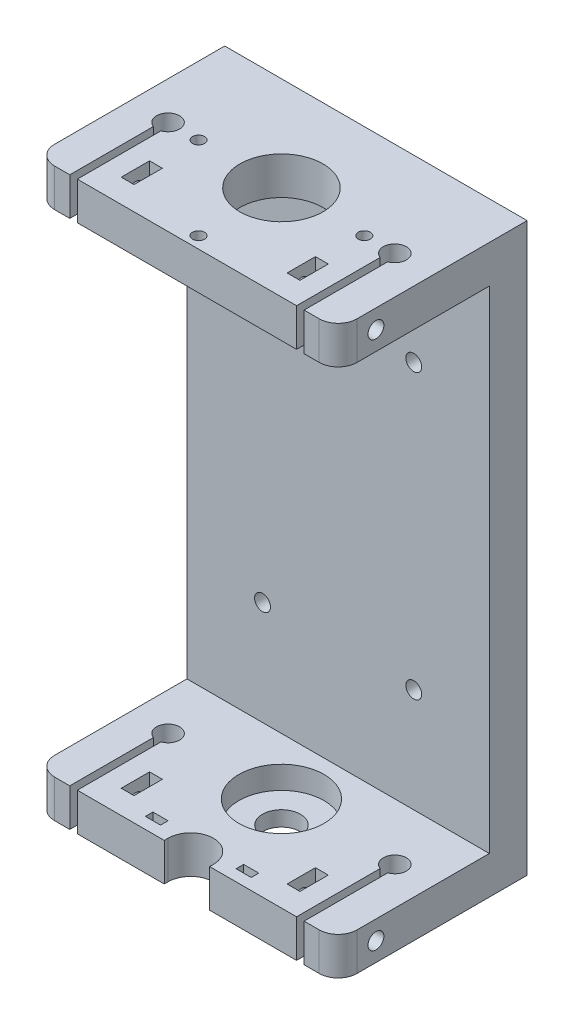
from build123d import *

# Parameters (mm, degrees)
SKETCH_1_W           = 80
SKETCH_1_H           = 150
EXTRUDE_1_DEPTH      = 10
SKETCH_4_R           = 11.25
EXTRUDE_3_DEPTH      = 10
SKETCH_5_R           = 11.25
SKETCH_5_R_2         = 5
EXTRUDE_4_DEPTH      = 4
SKETCH_6_R           = 2.1
CUT_EXTRUDE_1_DEPTH  = 24
SKETCH_7_W           = 3.4
SKETCH_7_H           = 7.5
CUT_EXTRUDE_2_DEPTH  = 24
SKETCH_8_R           = 2.1
CUT_EXTRUDE_3_DEPTH  = 24
SKETCH_9_W           = 80
SKETCH_9_H           = 40
SKETCH_9_R           = 11
SKETCH_9_R_2         = 1.6
EXTRUDE_5_DEPTH      = 10
FILLET_1_R           = 5
SKETCH_10_W          = 3.4
SKETCH_10_H          = 7.5
CUT_EXTRUDE_5_DEPTH  = 10
SKETCH_11_R          = 2.1
CUT_EXTRUDE_6_DEPTH  = 24
SKETCH_12_R          = 2.1
CUT_EXTRUDE_7_DEPTH  = 24
SKETCH_14_W          = 4
SKETCH_14_H          = 2
CUT_EXTRUDE_9_DEPTH  = 10
SKETCH_16_R          = 2.1
CUT_EXTRUDE_10_DEPTH = 11


with BuildPart() as part:
    # 草圖1 → 填料-伸長1 (new body)
    with BuildSketch(Plane.XY):
        Rectangle(SKETCH_1_W, SKETCH_1_H)
    extrude(amount=EXTRUDE_1_DEPTH)

    # 草圖4 → 填料-伸長3 (add)
    with BuildSketch(Plane.XZ.offset(75)):
        with BuildLine():
            ThreePointArc((-6, 49), (0, 43), (6, 49))
            Line((6, 49), (6, 50))
            Line((6, 50), (29, 50))
            Line((29, 50), (29, 27.881405907))
            ThreePointArc((29, 27.881405907), (30, 21.95), (31, 27.881405907))
            Line((31, 27.881405907), (31, 50))
            Line((31, 50), (40, 50))
            Line((40, 50), (40, 10))
            Line((40, 10), (-40, 10))
            Line((-40, 10), (-40, 50))
            Line((-40, 50), (-31, 50))
            Line((-31, 50), (-31, 27.881405907))
            ThreePointArc((-31, 27.881405907), (-30, 21.95), (-29, 27.881405907))
            Line((-29, 27.881405907), (-29, 50))
            Line((-29, 50), (-6, 50))
            Line((-6, 50), (-6, 49))
        make_face()
        with Locations((0, 25)):
            Circle(SKETCH_4_R, mode=Mode.SUBTRACT)
    extrude(amount=-EXTRUDE_3_DEPTH)

    # 草圖5 → 填料-伸長4 (add)
    with BuildSketch(Plane.XZ.offset(75)):
        with Locations((0, 25)):
            Circle(SKETCH_5_R)
        with Locations((0, 25)):
            Circle(SKETCH_5_R_2, mode=Mode.SUBTRACT)
    extrude(amount=-EXTRUDE_4_DEPTH)

    # 草圖6 → 除料-伸長1 (cut)
    with BuildSketch(Plane(origin=(40, 0, 0), x_dir=(0, 0, -1), z_dir=(1, 0, 0))):
        with Locations((-40, -70)):
            Circle(SKETCH_6_R)
    extrude(amount=-CUT_EXTRUDE_1_DEPTH, mode=Mode.SUBTRACT)

    # 草圖7 → 除料-伸長2 (cut)
    with BuildSketch(Plane.XZ.offset(75)):
        with Locations((-21.943112787, 40)):
            Rectangle(SKETCH_7_W, SKETCH_7_H)
        with Locations((21.943112787, 40)):
            Rectangle(SKETCH_7_W, SKETCH_7_H)
    extrude(amount=-CUT_EXTRUDE_2_DEPTH, mode=Mode.SUBTRACT)

    # 草圖8 → 除料-伸長3 (cut)
    with BuildSketch(Plane.ZY.offset(40)):
        with Locations((40, -70)):
            Circle(SKETCH_8_R)
    extrude(amount=-CUT_EXTRUDE_3_DEPTH, mode=Mode.SUBTRACT)

    # 草圖9 → 填料-伸長5 (add)
    with BuildSketch(Plane(origin=(0, 75, 0), x_dir=(1, 0, 0), z_dir=(0, 1, 0))):
        with Locations((0, -30)):
            Rectangle(SKETCH_9_W, SKETCH_9_H)
        with Locations((0, -25)):
            Circle(SKETCH_9_R, mode=Mode.SUBTRACT)
        with Locations((-21.920310217, -25)):
            Circle(SKETCH_9_R_2, mode=Mode.SUBTRACT)
        with Locations((0, -46.920310217)):
            Circle(SKETCH_9_R_2, mode=Mode.SUBTRACT)
        with Locations((21.920310217, -25)):
            Circle(SKETCH_9_R_2, mode=Mode.SUBTRACT)
    extrude(amount=-EXTRUDE_5_DEPTH)

    # 圓角1
    fillet_1_edges = [part.edges().sort_by_distance(p)[0] for p in [
        (40, 70, 50),
        (-40, 70, 50),
        (40, -70, 50),
        (-40, -70, 50),
    ]]
    fillet(fillet_1_edges, radius=FILLET_1_R)

    # 草圖10 → 除料-伸長5 (cut)
    with BuildSketch(Plane(origin=(0, 75, 0), x_dir=(1, 0, 0), z_dir=(0, 1, 0))):
        with BuildLine():
            Line((-30.992105359, -72.117230176), (-29, -72.117230176))
            Line((-29, -72.117230176), (-29, -27.881405907))
            ThreePointArc((-29, -27.881405907), (-30.004176302, -21.950002859), (-30.992105359, -27.884133658))
            Line((-30.992105359, -27.884133658), (-30.992105359, -72.117230176))
        make_face()
        with BuildLine():
            Line((29.001577897, -72.118320527), (31, -72.118320527))
            Line((31, -72.118320527), (31, -27.881405907))
            ThreePointArc((31, -27.881405907), (29.999164969, -21.950000114), (29.001577897, -27.881953036))
            Line((29.001577897, -27.881953036), (29.001577897, -72.118320527))
        make_face()
        with Locations((-21.943112787, -40)):
            Rectangle(SKETCH_10_W, SKETCH_10_H)
        with Locations((21.943112787, -40)):
            Rectangle(SKETCH_10_W, SKETCH_10_H)
    extrude(amount=-CUT_EXTRUDE_5_DEPTH, mode=Mode.SUBTRACT)

    # 草圖11 → 除料-伸長6 (cut)
    with BuildSketch(Plane(origin=(40, 0, 0), x_dir=(0, 0, -1), z_dir=(1, 0, 0))):
        with Locations((-40, 70)):
            Circle(SKETCH_11_R)
    extrude(amount=-CUT_EXTRUDE_6_DEPTH, mode=Mode.SUBTRACT)

    # 草圖12 → 除料-伸長7 (cut)
    with BuildSketch(Plane.ZY.offset(40)):
        with Locations((40, 70)):
            Circle(SKETCH_12_R)
    extrude(amount=-CUT_EXTRUDE_7_DEPTH, mode=Mode.SUBTRACT)

    # 草圖14 → 除料-伸長9 (cut)
    with BuildSketch(Plane.XZ.offset(75)):
        with Locations((-12, 46)):
            Rectangle(SKETCH_14_W, SKETCH_14_H)
        with Locations((12, 46)):
            Rectangle(SKETCH_14_W, SKETCH_14_H)
    extrude(amount=-CUT_EXTRUDE_9_DEPTH, mode=Mode.SUBTRACT)

    # 草圖16 → 除料-伸長10 (cut, through all)
    with BuildSketch(Plane.XY.offset(10)):
        with Locations((-20, 37.5)):
            Circle(SKETCH_16_R)
        with Locations((20, 37.5)):
            Circle(SKETCH_16_R)
        with Locations((20, -37.5)):
            Circle(SKETCH_16_R)
        with Locations((-20, -37.5)):
            Circle(SKETCH_16_R)
    extrude(amount=-CUT_EXTRUDE_10_DEPTH, mode=Mode.SUBTRACT)


solid = part.part
